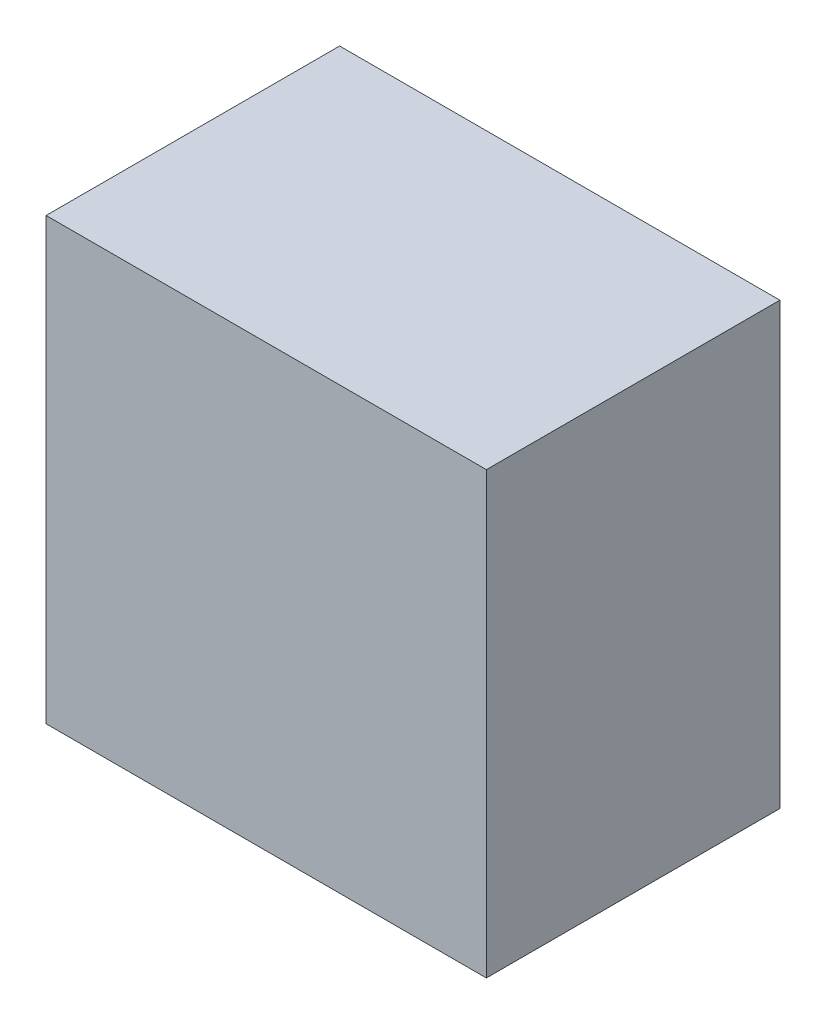
from build123d import *

# Parameters (mm, degrees)
SKETCH1_W           = 15
SKETCH1_H           = 15
BOSS_EXTRUDE1_DEPTH = 10
BOSS_EXTRUDE2_DEPTH = 1.5


with BuildPart() as part:
    # Sketch1 → Boss-Extrude1 (new body)
    with BuildSketch(Plane.XY):
        with Locations((7.5, -7.5)):
            Rectangle(SKETCH1_W, SKETCH1_H)
    extrude(amount=BOSS_EXTRUDE1_DEPTH)

    # Sketch2 → Boss-Extrude2 (add, symmetric)
    with BuildSketch(Plane(origin=(7.5, 0, 0), x_dir=(0, 0, -1), z_dir=(1, 0, 0))):
        with BuildLine():
            ThreePointArc((3, -5), (0.5, -7.5), (3, -10))
            Line((3, -10), (3, -8.5))
            ThreePointArc((3, -8.5), (2, -7.5), (3, -6.5))
            Line((3, -6.5), (3, -5))
        make_face()
        with BuildLine():
            Line((3, -8.5), (3, -10))
            ThreePointArc((3, -10), (4.767766953, -9.267766953), (5.5, -7.5))
            ThreePointArc((5.5, -7.5), (4.767766953, -5.732233047), (3, -5))
            Line((3, -5), (3, -6.5))
            ThreePointArc((3, -6.5), (3.707106781, -6.792893219), (4, -7.5))
            ThreePointArc((4, -7.5), (3.707106781, -8.207106781), (3, -8.5))
        make_face()
        with BuildLine():
            Line((0, -10), (3, -10))
            ThreePointArc((3, -10), (0.5, -7.5), (3, -5))
            Line((3, -5), (0, -5))
            Line((0, -5), (0, -10))
        make_face()
    extrude(amount=BOSS_EXTRUDE2_DEPTH, both=True)


solid = part.part
